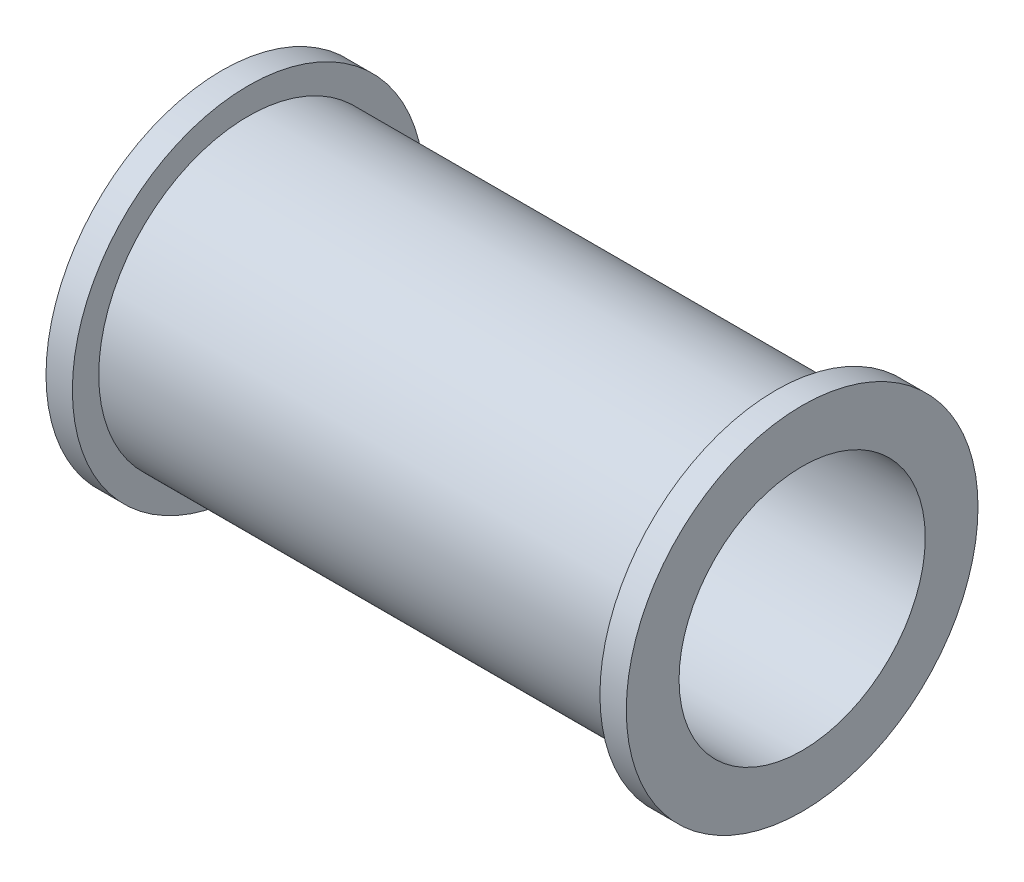
from build123d import *

# Parameters (mm, degrees)
SKETCH_3_R          = 7
CUT_EXTRUDE_1_DEPTH = 34


with BuildPart() as part:
    # Эскиз2 → Повернуть1 (revolve)
    with BuildSketch(Plane(origin=(0, 0, 0), x_dir=(1, 0, 0), z_dir=(0, 1, 0))):
        Polygon((0, 0), (0, 10), (1.5, 10), (1.5, 8.5), (31.5, 8.5), (31.5, 10), (33, 10), (33, 0), align=None)
    revolve(axis=Axis((33, 0, 0), (-1, 0, 0)))

    # Эскиз3 → Вырез-Вытянуть1 (cut, through all)
    with BuildSketch(Plane(origin=(33, 0, 0), x_dir=(0, 0, -1), z_dir=(1, 0, 0))):
        Circle(SKETCH_3_R)
    extrude(amount=-CUT_EXTRUDE_1_DEPTH, mode=Mode.SUBTRACT)


solid = part.part
